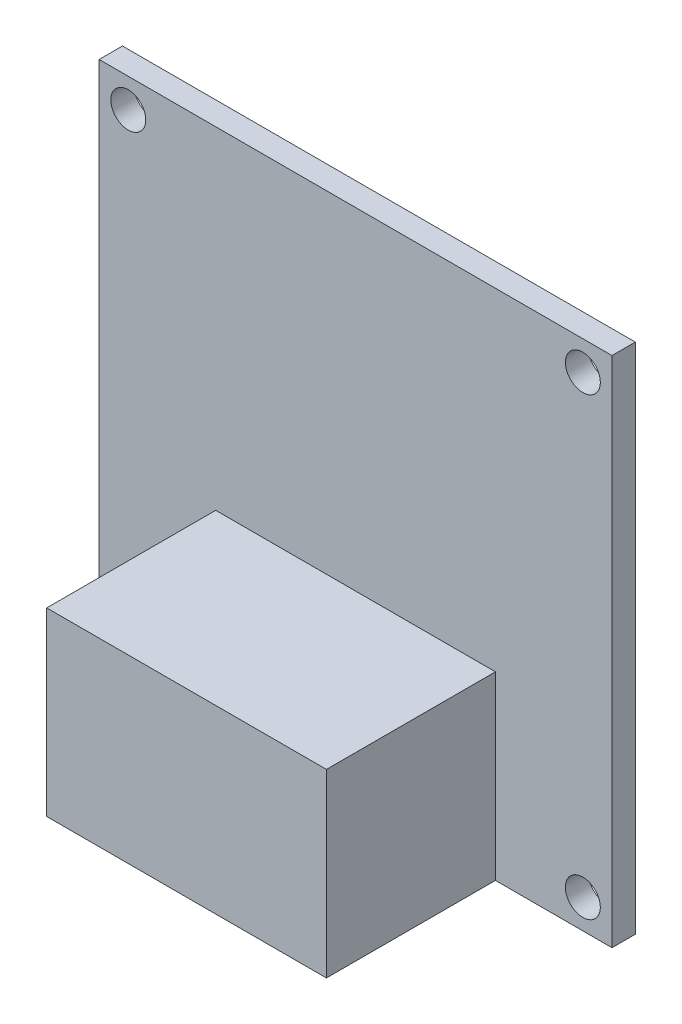
from build123d import *

# Parameters (mm, degrees)
CROQUIS1_W              = 44
CROQUIS1_H              = 44
CROQUIS1_R              = 1.5
SALIENTE_EXTRUIR1_DEPTH = 2
CROQUIS2_W              = 24
CROQUIS2_H              = 15.5
SALIENTE_EXTRUIR2_DEPTH = 14.5


with BuildPart() as part:
    # Croquis1 → Saliente-Extruir1 (new body)
    with BuildSketch(Plane.XY):
        Rectangle(CROQUIS1_W, CROQUIS1_H)
        with Locations((19.5, 19.5)):
            Circle(CROQUIS1_R, mode=Mode.SUBTRACT)
        with Locations((19.5, -19.5)):
            Circle(CROQUIS1_R, mode=Mode.SUBTRACT)
        with Locations((-19.5, -19.5)):
            Circle(CROQUIS1_R, mode=Mode.SUBTRACT)
        with Locations((-19.5, 19.5)):
            Circle(CROQUIS1_R, mode=Mode.SUBTRACT)
    extrude(amount=SALIENTE_EXTRUIR1_DEPTH)


with BuildPart() as body_2:
    # Croquis2 → Saliente-Extruir2 (new body)
    with BuildSketch(Plane.XY.offset(2)):
        with Locations((0, -14.25)):
            Rectangle(CROQUIS2_W, CROQUIS2_H)
    extrude(amount=SALIENTE_EXTRUIR2_DEPTH)


solid = Compound([part.part, body_2.part])
